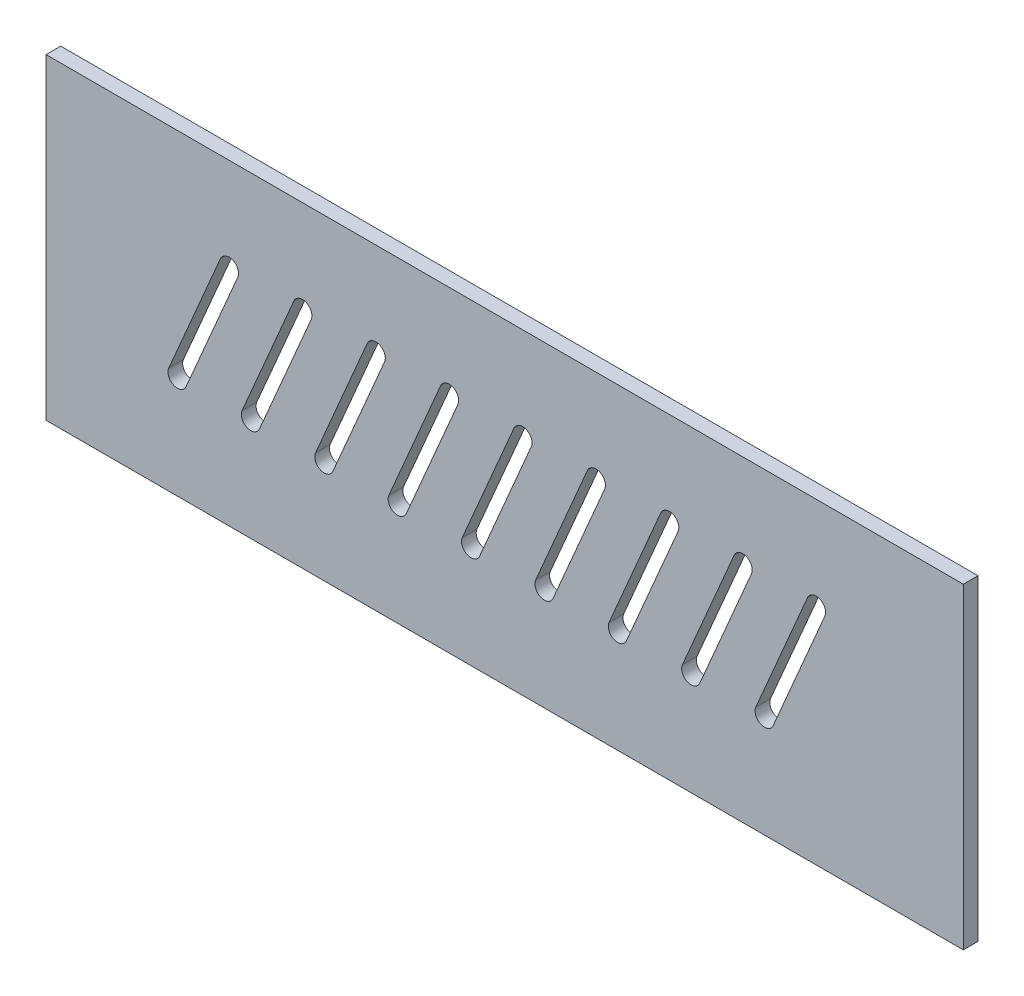
from build123d import *

# Parameters (mm, degrees)
SKETCH1_W           = 125
SKETCH1_H           = 65
BOSS_EXTRUDE1_DEPTH = 2
SKETCH2_W           = 125
SKETCH2_H           = 21.840489908
CUT_EXTRUDE1_DEPTH  = 3
CUT_EXTRUDE2_DEPTH  = 20
LPATTERN1_COUNT     = 9
LPATTERN1_PITCH     = 10


with BuildPart() as part:
    # Sketch1 → Boss-Extrude1 (new body)
    with BuildSketch(Plane.XY):
        Rectangle(SKETCH1_W, SKETCH1_H)
    extrude(amount=BOSS_EXTRUDE1_DEPTH)

    # Sketch2 → Cut-Extrude1 (cut, through all)
    with BuildSketch(Plane.XY.offset(2)):
        with Locations((0, 21.579755046)):
            Rectangle(SKETCH2_W, SKETCH2_H)
    extrude(amount=-CUT_EXTRUDE1_DEPTH, mode=Mode.SUBTRACT)

    # Sketch3 → Cut-Extrude2 (cut)
    with BuildSketch(Plane.XY.offset(2)):
        with BuildLine():
            Line((-45.774182217, -17.977174407), (-38.733037936, -1.547837751))
            ThreePointArc((-38.733037936, -1.547837751), (-37.046940168, -0.873398644), (-36.372501061, -2.559496412))
            Line((-36.372501061, -2.559496412), (-43.413645342, -18.988833068))
            ThreePointArc((-43.413645342, -18.988833068), (-45.09974311, -19.663272175), (-45.774182217, -17.977174407))
        make_face()
    cut_extrude2 = extrude(amount=-CUT_EXTRUDE2_DEPTH, mode=Mode.SUBTRACT)

    # LPattern1: Cut-Extrude2 ×9
    with Locations(*[(i * LPATTERN1_PITCH, 0, 0) for i in range(1, LPATTERN1_COUNT)]):
        add(cut_extrude2, mode=Mode.SUBTRACT)


solid = part.part
